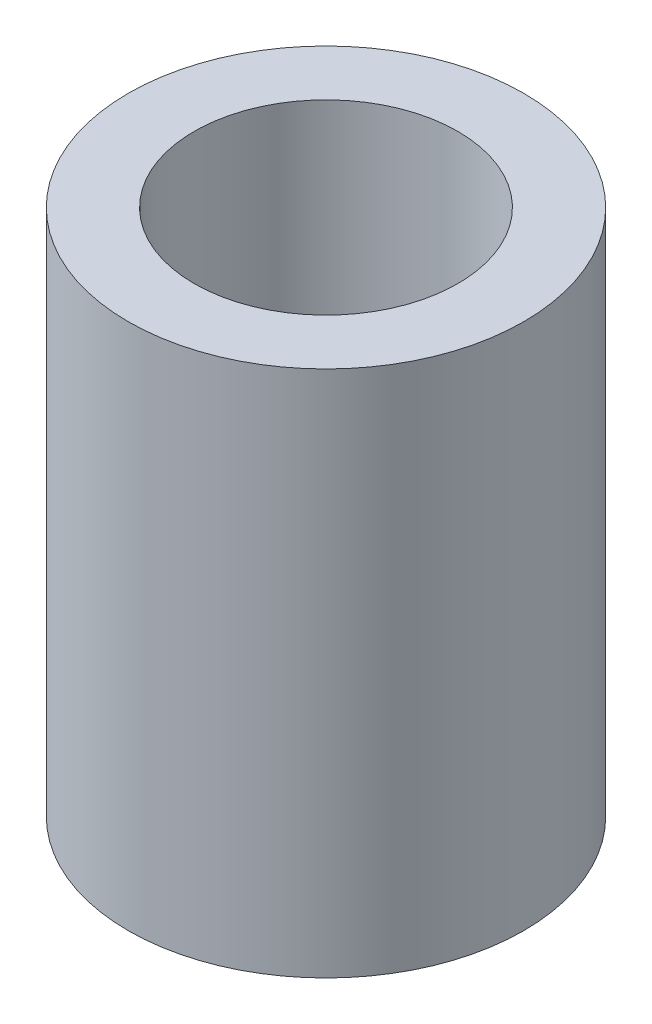
from build123d import *

# Parameters (mm, degrees)
SKETCH1_R           = 4.7625
SKETCH1_R_2         = 3.175
BOSS_EXTRUDE1_DEPTH = 12.7


with BuildPart() as part:
    # Sketch1 → Boss-Extrude1 (new body)
    with BuildSketch(Plane(origin=(0, 0, 0), x_dir=(1, 0, 0), z_dir=(0, 1, 0))):
        Circle(SKETCH1_R)
        Circle(SKETCH1_R_2, mode=Mode.SUBTRACT)
    extrude(amount=BOSS_EXTRUDE1_DEPTH)


solid = part.part
